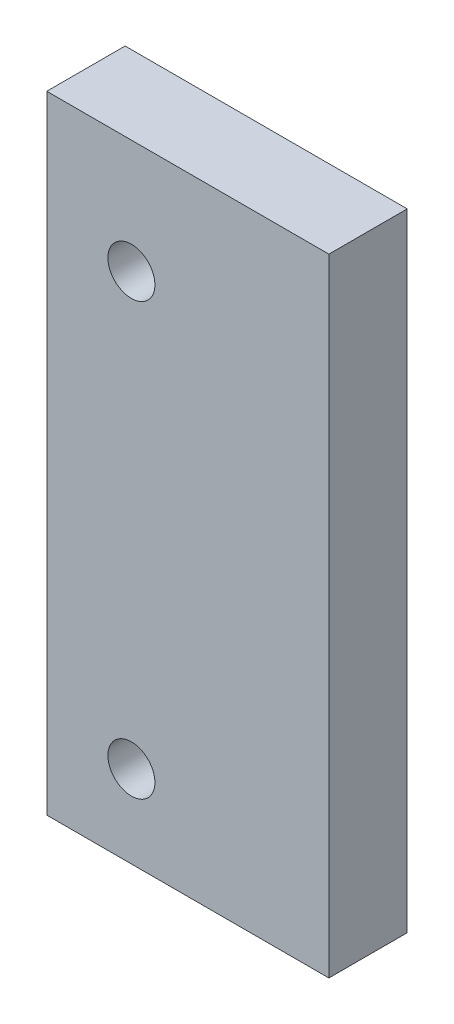
from build123d import *

# Parameters (mm, degrees)
SKETCH2_W           = 9
SKETCH2_H           = 20
BOSS_EXTRUDE1_DEPTH = 2.5
SKETCH3_R           = 0.75
CUT_EXTRUDE1_DEPTH  = 3.5


with BuildPart() as part:
    # Sketch2 → Boss-Extrude1 (new body)
    with BuildSketch(Plane.XY):
        with Locations((4.5, 10)):
            Rectangle(SKETCH2_W, SKETCH2_H)
    extrude(amount=BOSS_EXTRUDE1_DEPTH)

    # Sketch3 → Cut-Extrude1 (cut, through all)
    with BuildSketch(Plane.XY.offset(2.5)):
        with Locations((2.7, 16.375)):
            Circle(SKETCH3_R)
        with Locations((2.7, 2.625)):
            Circle(SKETCH3_R)
    extrude(amount=-CUT_EXTRUDE1_DEPTH, mode=Mode.SUBTRACT)


solid = part.part
